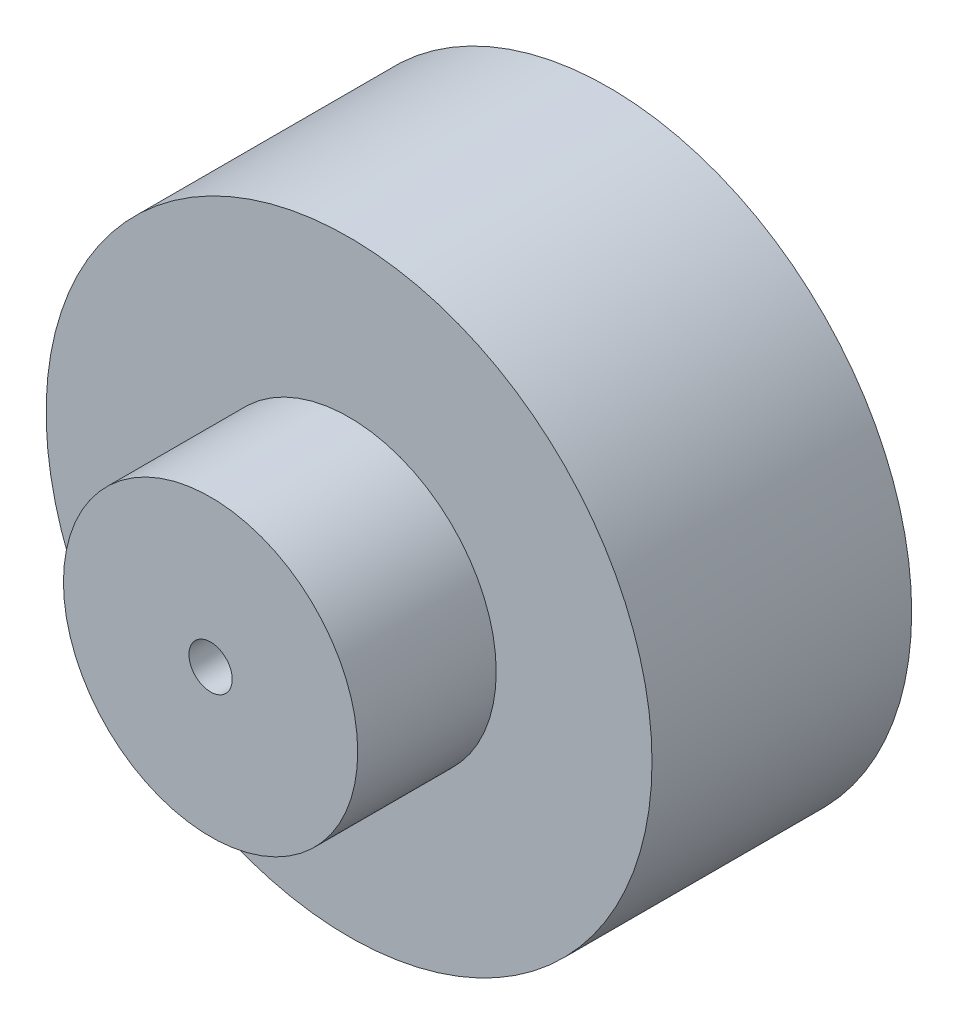
from build123d import *

# Parameters (mm, degrees)
SKETCH1_R           = 17.5
BOSS_EXTRUDE1_DEPTH = 15
SKETCH2_R           = 8.5
BOSS_EXTRUDE2_DEPTH = 8
SKETCH3_R           = 1.25
CUT_EXTRUDE1_DEPTH  = 20


with BuildPart() as part:
    # Sketch1 → Boss-Extrude1 (new body)
    with BuildSketch(Plane.XY):
        Circle(SKETCH1_R)
    extrude(amount=BOSS_EXTRUDE1_DEPTH)

    # Sketch2 → Boss-Extrude2 (add)
    with BuildSketch(Plane.XY.offset(15)):
        Circle(SKETCH2_R)
    extrude(amount=BOSS_EXTRUDE2_DEPTH)

    # Sketch3 → Cut-Extrude1 (cut)
    with BuildSketch(Plane.XY.offset(23)):
        Circle(SKETCH3_R)
    extrude(amount=-CUT_EXTRUDE1_DEPTH, mode=Mode.SUBTRACT)


solid = part.part
